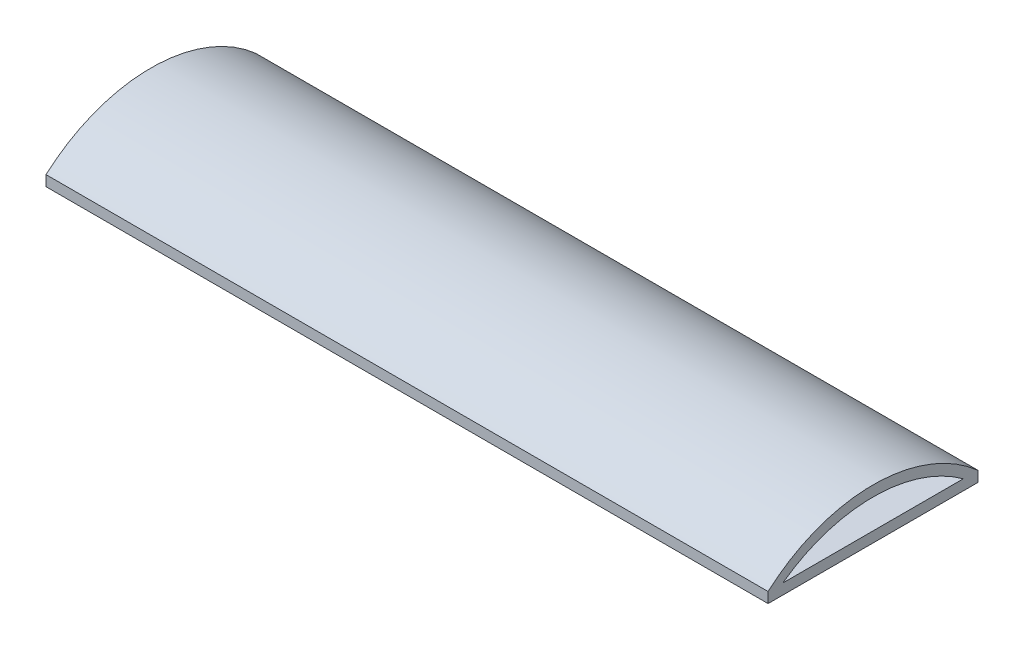
from build123d import *

# Parameters (mm, degrees)
SKETCH_1_W      = 34.4
SKETCH_1_H      = 10
EXTRUDE_1_DEPTH = 0.5
EXTRUDE_2_DEPTH = 34.4


with BuildPart() as part:
    # Эскиз1 → Бобышка-Вытянуть1 (new body)
    with BuildSketch(Plane(origin=(0, 0, 0), x_dir=(1, 0, 0), z_dir=(0, 1, 0))):
        Rectangle(SKETCH_1_W, SKETCH_1_H)
    extrude(amount=EXTRUDE_1_DEPTH)

    # Эскиз2 → Бобышка-Вытянуть2 (add, through all)
    with BuildSketch(Plane.ZY.offset(17.2)):
        with BuildLine():
            ThreePointArc((5, 0.5), (0, 2.400988005), (-5, 0.5))
            Line((-5, 0.5), (-4.3, 0.5))
            ThreePointArc((-4.3, 0.5), (0, 1.9), (4.3, 0.5))
            Line((4.3, 0.5), (5, 0.5))
        make_face()
    extrude(amount=-EXTRUDE_2_DEPTH)


solid = part.part
